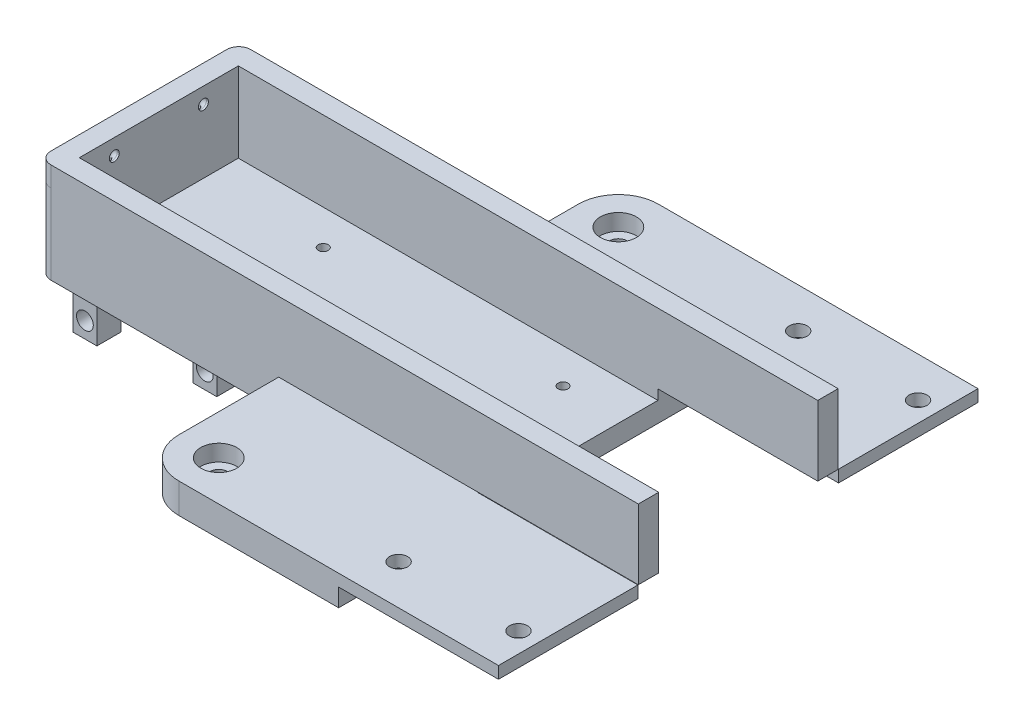
from build123d import *

# Parameters (mm, degrees)
SKETCH_1_W                   = 300
SKETCH_1_H                   = 50
EXTRUDE_1_DEPTH              = 10
SKETCH_2_W                   = 300
SKETCH_2_H                   = 10.1
SKETCH_2_H_2                 = 9.2
CUT_EXTRUDE_1_DEPTH          = 5
FILLET_1_R                   = 3
CUT_EXTRUDE_START            = -5
SKETCH_10_W                  = 39.8
SKETCH_10_H                  = 15
CUT_EXTRUDE_4_DEPTH          = 145
CUT_EXTRUDE_6_DEPTH          = 51
SKETCH_13_W                  = 50
SKETCH_13_H                  = 35
EXTRUDE_2_DEPTH              = 7.5
HOLE_WIZARD_M4_1_D           = 4.5
HOLE_WIZARD_M4_1_CBORE_D     = 9
HOLE_WIZARD_M4_1_CBORE_DEPTH = 4.1
SKETCH_16_W                  = 6
SKETCH_16_H                  = 6
EXTRUDE_3_DEPTH              = 8
SKETCH_17_R                  = 2.1
CUT_EXTRUDE_7_DEPTH          = 82.5
SKETCH_19_W                  = 6
SKETCH_19_H                  = 6
EXTRUDE_4_DEPTH              = 12
SKETCH_20_R                  = 2.1
CUT_EXTRUDE_9_DEPTH          = 82.5
SKETCH_23_W                  = 34.9
SKETCH_23_H                  = 3
EXTRUDE_9_DEPTH              = 40
HOLE_WIZARD_M4_1_2_D         = 4.5
FILLET_2_R                   = 0.5
SKETCH_27_W                  = 5
SKETCH_27_H                  = 32.4
EXTRUDE_10_DEPTH             = 5
HOLE_WIZARD_M3_1_D           = 2.5
HOLE_WIZARD_M3_1_DEPTH       = 5
EXTRUDE_12_DEPTH             = 5
FILLET_3_R                   = 3
SKETCH_21_R                  = 1.25
FILLET_4_R                   = 10


with BuildPart() as part:
    # 스케치1 → 보스-돌출1 (new body, symmetric)
    with BuildSketch(Plane(origin=(0, 0, 0), x_dir=(1, 0, 0), z_dir=(0, 1, 0))):
        Rectangle(SKETCH_1_W, SKETCH_1_H)
    extrude(amount=EXTRUDE_1_DEPTH, both=True)

    # 스케치2 → 컷-돌출1 (cut)
    with BuildSketch(Plane(origin=(0, 10, 0), x_dir=(1, 0, 0), z_dir=(0, 1, 0))):
        with Locations((0, 11.15)):
            Rectangle(SKETCH_2_W, SKETCH_2_H)
        Rectangle(SKETCH_2_W, SKETCH_2_H_2)
        with Locations((0, -11.15)):
            Rectangle(SKETCH_2_W, SKETCH_2_H)
    extrude(amount=-CUT_EXTRUDE_1_DEPTH, mode=Mode.SUBTRACT)

    # 필렛1
    fillet_1_edges = [part.edges().sort_by_distance(p)[0] for p in [
        (150, 0, 25),
        (-150, 0, 25),
        (-150, 0, -25),
        (150, 0, -25),
    ]]
    fillet(fillet_1_edges, radius=FILLET_1_R)

    # 스케치10 → 컷-돌출4 (cut)
    with BuildSketch(Plane.ZY.offset(150).offset(CUT_EXTRUDE_START)):
        with Locations((0, 2.5)):
            Rectangle(SKETCH_10_W, SKETCH_10_H)
    extrude(amount=-CUT_EXTRUDE_4_DEPTH, mode=Mode.SUBTRACT)

    # 스케치12 → 컷-돌출6 (cut, through all)
    with BuildSketch(Plane.XY.offset(25)):
        Polygon((-40, -10), (-40, -2.5), (0, -2.5), (0, 10), (150, 10), (150, -10), align=None)
    extrude(amount=-CUT_EXTRUDE_6_DEPTH, mode=Mode.SUBTRACT)

    # 스케치13 → 보스-돌출2 (add)
    with BuildSketch(Plane(origin=(0, -10, 0), x_dir=(-1, 0, 0), z_dir=(0, -1, 0))):
        with Locations((65, -42.5)):
            Rectangle(SKETCH_13_W, SKETCH_13_H)
        with Locations((65, 42.5)):
            Rectangle(SKETCH_13_W, SKETCH_13_H)
    extrude(amount=-EXTRUDE_2_DEPTH)

    # Hole Wizard M4 _ _ _ _1 (through all)
    with Locations(Plane(origin=(0, -2.5, 0), x_dir=(1, 0, 0), z_dir=(0, 1, 0))):
        with Locations((-80, 50), (-80, -50)):
            CounterBoreHole(HOLE_WIZARD_M4_1_D / 2, HOLE_WIZARD_M4_1_CBORE_D / 2, HOLE_WIZARD_M4_1_CBORE_DEPTH)

    # 스케치16 → 보스-돌출3 (add)
    with BuildSketch(Plane(origin=(0, -10, 0), x_dir=(-1, 0, 0), z_dir=(0, -1, 0))):
        with Locations((112, -18.5)):
            Rectangle(SKETCH_16_W, SKETCH_16_H)
        with Locations((112, -5)):
            Rectangle(SKETCH_16_W, SKETCH_16_H)
        with Locations((112, 5)):
            Rectangle(SKETCH_16_W, SKETCH_16_H)
        with Locations((112, 18.5)):
            Rectangle(SKETCH_16_W, SKETCH_16_H)
    extrude(amount=EXTRUDE_3_DEPTH)

    # 스케치17 → 컷-돌출7 (cut, through all)
    with BuildSketch(Plane.XY.offset(21.5)):
        with Locations((-112, -14)):
            Circle(SKETCH_17_R)
    extrude(amount=-CUT_EXTRUDE_7_DEPTH, mode=Mode.SUBTRACT)

    # 스케치19 → 보스-돌출4 (add)
    with BuildSketch(Plane.XZ.offset(10)):
        with Locations((-142, 18.5)):
            Rectangle(SKETCH_19_W, SKETCH_19_H)
        with Locations((-142, 4.5)):
            Rectangle(SKETCH_19_W, SKETCH_19_H)
        with Locations((-142, -4.5)):
            Rectangle(SKETCH_19_W, SKETCH_19_H)
        with Locations((-142, -18.5)):
            Rectangle(SKETCH_19_W, SKETCH_19_H)
    extrude(amount=EXTRUDE_4_DEPTH)

    # 스케치20 → 컷-돌출9 (cut, through all)
    with BuildSketch(Plane.XY.offset(21.5)):
        with Locations((-142, -18)):
            Circle(SKETCH_20_R)
    extrude(amount=-CUT_EXTRUDE_9_DEPTH, mode=Mode.SUBTRACT)

    # 스케치23 → 보스-돌출9 (add)
    with BuildSketch(Plane(origin=(-40, 0, 0), x_dir=(0, 0, -1), z_dir=(1, 0, 0))):
        with Locations((-42.55, -4)):
            Rectangle(SKETCH_23_W, SKETCH_23_H)
        with Locations((42.55, -4)):
            Rectangle(SKETCH_23_W, SKETCH_23_H)
    extrude(amount=EXTRUDE_9_DEPTH)

    # Hole Wizard M4 _ _1 2 (through all)
    with Locations(Plane(origin=(0, -2.5, 0), x_dir=(1, 0, 0), z_dir=(0, 1, 0))):
        with Locations((-35, 50), (-5, 50), (-5, -50), (-35, -50)):
            Hole(HOLE_WIZARD_M4_1_2_D / 2)

    # 필렛2
    fillet_2_edges = [part.edges().sort_by_distance(p)[0] for p in [
        (-109, -14, 15.5),
    ]]
    fillet(fillet_2_edges, radius=FILLET_2_R)

    # 스케치27 → 보스-돌출10 (add)
    with BuildSketch(Plane(origin=(0, 5, 0), x_dir=(1, 0, 0), z_dir=(0, 1, 0))):
        with Locations((-147.5, 0)):
            Rectangle(SKETCH_27_W, SKETCH_27_H)
    extrude(amount=EXTRUDE_10_DEPTH)

    # M3 나사 구멍1
    with Locations(Plane(origin=(0, -5, 0), x_dir=(1, 0, 0), z_dir=(0, 1, 0))):
        with Locations((-115, 11.15), (-115, -11.15), (-55, 11.15), (-55, -11.15)):
            Hole(HOLE_WIZARD_M3_1_D / 2, depth=HOLE_WIZARD_M3_1_DEPTH)

    # 스케치34 → 보스-돌출12 (add)
    with BuildSketch(Plane(origin=(0, 10, 0), x_dir=(1, 0, 0), z_dir=(0, 1, 0))):
        Polygon((-150, 25), (-150, -25), (0, -25), (0, -19.9), (-145, -19.9), (-145, 19.9), (0, 19.9), (0, 25), align=None)
    extrude(amount=EXTRUDE_12_DEPTH)

    # 필렛3
    fillet_3_edges = [part.edges().sort_by_distance(p)[0] for p in [
        (-150, 12.5, 25),
        (-150, 12.5, -25),
    ]]
    fillet(fillet_3_edges, radius=FILLET_3_R)

    # 컷-스윕1: sweep along a path in 스케치22
    with BuildLine(Plane(origin=(0, 0, 11.15), x_dir=(-1, 0, 0), z_dir=(0, 0, -1))) as sweep_1_path:
        Line((147.5, -10), (147.5, 9))
        ThreePointArc((147.5, 9), (146.914213562, 10.414213562), (145.5, 11))
        Line((145.5, 11), (144.5, 11))
    # 스케치21 → 컷-스윕1 (sweep, cut)
    with BuildSketch(Plane(origin=(0, -10, 0), x_dir=(-1, 0, 0), z_dir=(0, -1, 0))):
        with Locations((147.5, -11.15)):
            Circle(SKETCH_21_R)
        with Locations((147.5, 11.15)):
            Circle(SKETCH_21_R)
    sweep(path=sweep_1_path.line, mode=Mode.SUBTRACT)

    # 필렛4
    fillet_4_edges = [part.edges().sort_by_distance(p)[0] for p in [
        (-90, -6.25, 60),
        (-90, -6.25, -60),
    ]]
    fillet(fillet_4_edges, radius=FILLET_4_R)


solid = part.part
